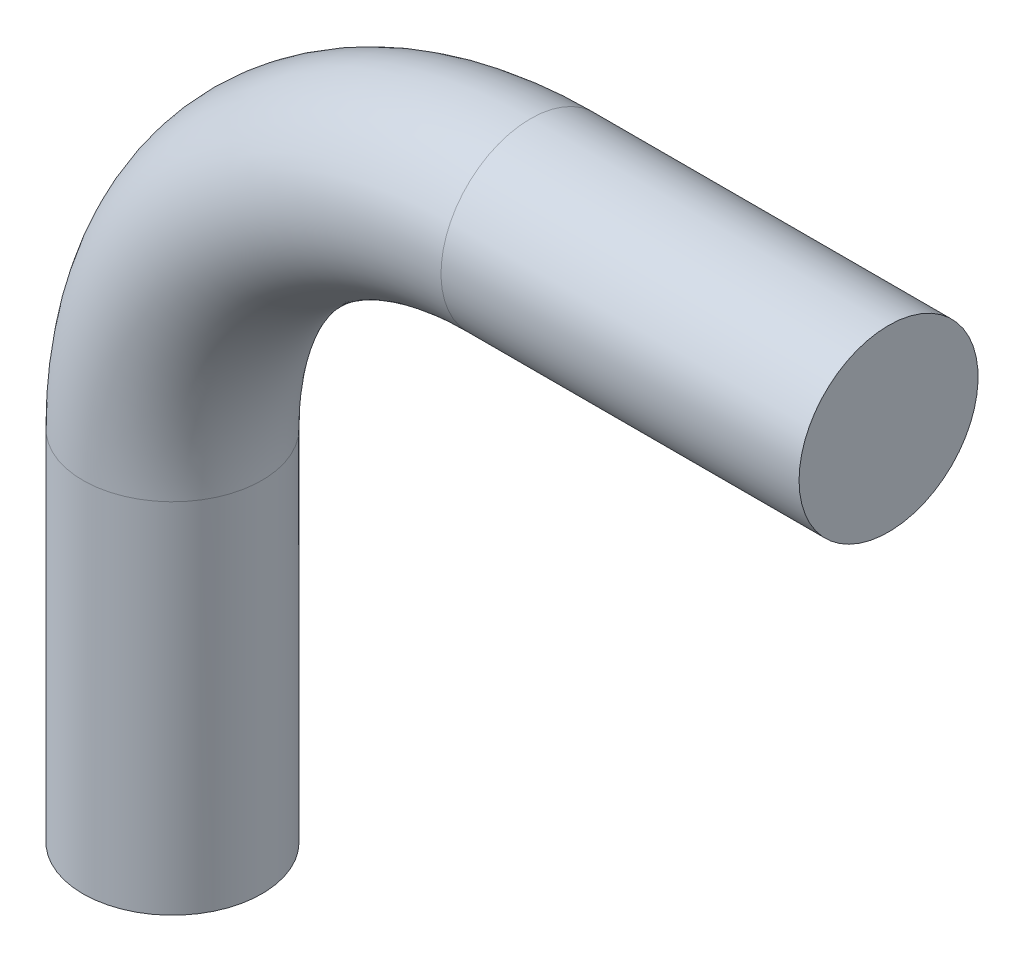
from build123d import *

# Parameters (mm, degrees)
SKETCH1_R = 25


with BuildPart() as part:
    # Sweep1: sweep along a path in Sketch2
    with BuildLine(Plane.XY) as sweep1_path:
        Line((0, 0), (0, 100))
        ThreePointArc((0, 100), (29.289321881, 170.710678119), (100, 200))
        Line((100, 200), (200, 200))
    # Sketch1 → Sweep1 (sweep)
    with BuildSketch(Plane(origin=(0, 0, 0), x_dir=(1, 0, 0), z_dir=(0, 1, 0))):
        Circle(SKETCH1_R)
    sweep(path=sweep1_path.line)


solid = part.part
